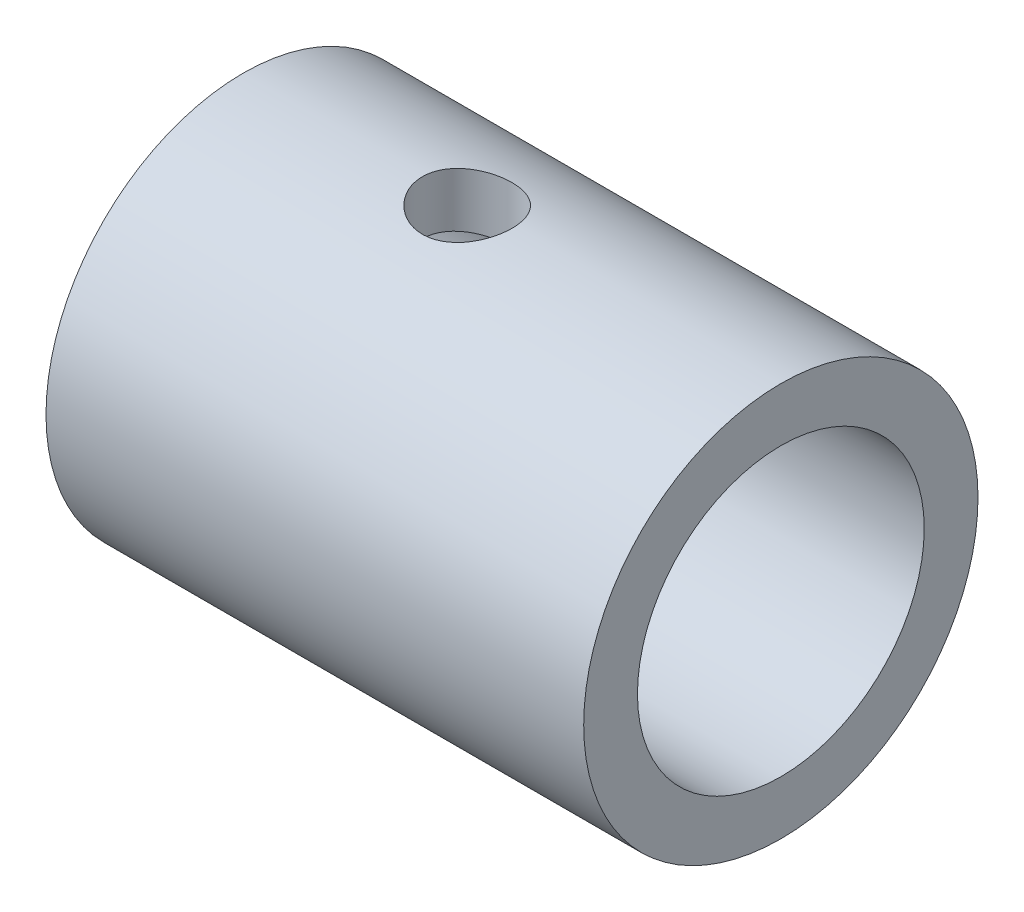
from build123d import *

# Parameters (mm, degrees)
SKETCH_1_R          = 11
SKETCH_1_R_2        = 8
EXTRUDE_1_DEPTH     = 30
SKETCH_2_R          = 2.5
CUT_EXTRUDE_1_DEPTH = 12


with BuildPart() as part:
    # 草图1 → 凸台-拉伸1 (new body)
    with BuildSketch(Plane(origin=(0, 0, 0), x_dir=(0, 0, -1), z_dir=(1, 0, 0))):
        Circle(SKETCH_1_R)
        Circle(SKETCH_1_R_2, mode=Mode.SUBTRACT)
    extrude(amount=-EXTRUDE_1_DEPTH)

    # 草图2 → 切除-拉伸1 (cut, through all)
    with BuildSketch(Plane(origin=(0, 0, 0), x_dir=(1, 0, 0), z_dir=(0, 1, 0))):
        with Locations((-17.5, 0)):
            Circle(SKETCH_2_R)
    extrude(amount=CUT_EXTRUDE_1_DEPTH, mode=Mode.SUBTRACT)


solid = part.part
